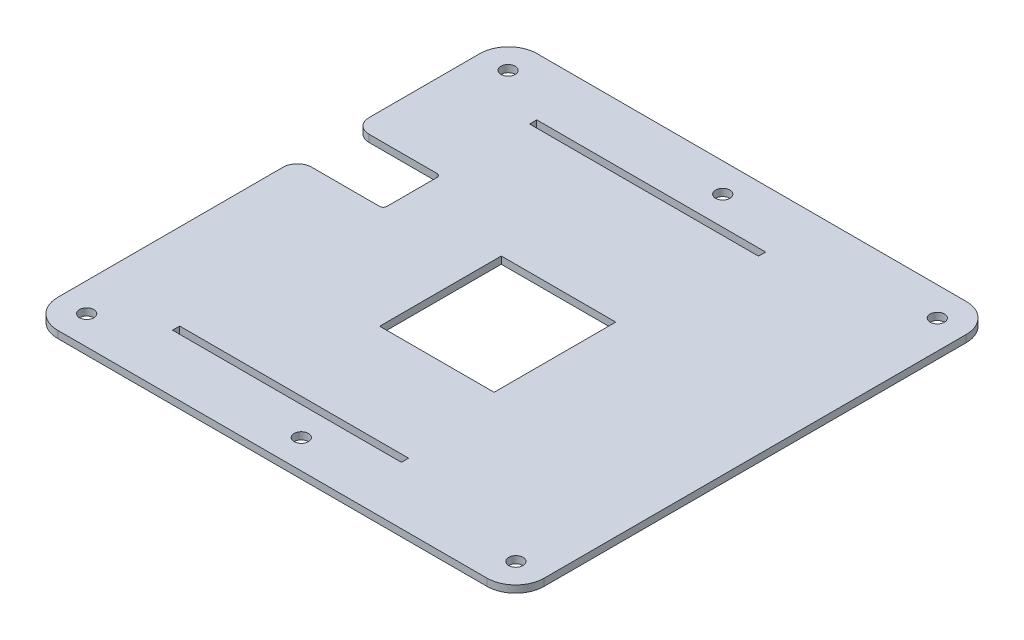
from build123d import *

# Parameters (mm, degrees)
SKETCH1_W               = 254
SKETCH1_H               = 212.725
SKETCH1_W_2             = 101.6
SKETCH1_H_2             = 3.175
SKETCH1_W_3             = 50.8
SKETCH1_H_3             = 53.975
SKETCH1_W_4             = 57.15
SKETCH1_H_4             = 25.4
BOSS_EXTRUDE1_DEPTH     = 3.175
SKETCH3_W               = 38.1
SKETCH3_H               = 212.725
CUT_EXTRUDE2_DEPTH      = 4.175
FILLET1_R               = 12.7
SKETCH2_R               = 3.175
CUT_EXTRUDE1_DEPTH      = 1
CUT_EXTRUDE1_DEPTH_BACK = 4.175
FILLET2_R               = 1.5875
FILLET3_R               = 6.35


with BuildPart() as part:
    # Sketch1 → Boss-Extrude1 (new body)
    with BuildSketch(Plane(origin=(0, 0, 0), x_dir=(1, 0, 0), z_dir=(0, 1, 0))):
        Rectangle(SKETCH1_W, SKETCH1_H)
        with Locations((0, 79.248)):
            Rectangle(SKETCH1_W_2, SKETCH1_H_2, mode=Mode.SUBTRACT)
        with Locations((0, -79.248)):
            Rectangle(SKETCH1_W_2, SKETCH1_H_2, mode=Mode.SUBTRACT)
        with Locations((19.05, -6.35)):
            Rectangle(SKETCH1_W_3, SKETCH1_H_3, mode=Mode.SUBTRACT)
        with Locations((-79.375, 25.4)):
            Rectangle(SKETCH1_W_4, SKETCH1_H_4, mode=Mode.SUBTRACT)
    extrude(amount=BOSS_EXTRUDE1_DEPTH)

    # Sketch3 → Cut-Extrude2 (cut, through all)
    with BuildSketch(Plane(origin=(0, 3.175, 0), x_dir=(1, 0, 0), z_dir=(0, 1, 0))):
        with Locations((-107.95, 0)):
            Rectangle(SKETCH3_W, SKETCH3_H)
    extrude(amount=-CUT_EXTRUDE2_DEPTH, mode=Mode.SUBTRACT)

    # Fillet1
    fillet1_edges = [part.edges().sort_by_distance(p)[0] for p in [
        (127, 1.5875, 106.3625),
        (-88.9, 1.5875, -106.3625),
        (127, 1.5875, -106.3625),
        (-88.9, 1.5875, 106.3625),
    ]]
    fillet(fillet1_edges, radius=FILLET1_R)

    # Sketch2 → Cut-Extrude1 (cut, two sides)
    with BuildSketch(Plane(origin=(0, 3.175, 0), x_dir=(1, 0, 0), z_dir=(0, 1, 0))) as cut_extrude1_sk:
        with Locations((114.3, 93.5355)):
            Circle(SKETCH2_R)
        with Locations((114.3, -93.5355)):
            Circle(SKETCH2_R)
        with Locations((-76.2, -93.5355)):
            Circle(SKETCH2_R)
        with Locations((-76.2, 93.5355)):
            Circle(SKETCH2_R)
        with Locations((19.05, -93.5355)):
            Circle(SKETCH2_R)
        with Locations((19.05, 93.5355)):
            Circle(SKETCH2_R)
    extrude(amount=CUT_EXTRUDE1_DEPTH, mode=Mode.SUBTRACT)
    extrude(cut_extrude1_sk.sketch, amount=-CUT_EXTRUDE1_DEPTH_BACK, mode=Mode.SUBTRACT)

    # Fillet2
    fillet2_edges = [part.edges().sort_by_distance(p)[0] for p in [
        (-50.8, 1.5875, -12.7),
        (-50.8, 1.5875, -38.1),
    ]]
    fillet(fillet2_edges, radius=FILLET2_R)

    # Fillet3
    fillet3_edges = [part.edges().sort_by_distance(p)[0] for p in [
        (-88.9, 1.5875, -12.7),
        (-88.9, 1.5875, -38.1),
    ]]
    fillet(fillet3_edges, radius=FILLET3_R)


solid = part.part
